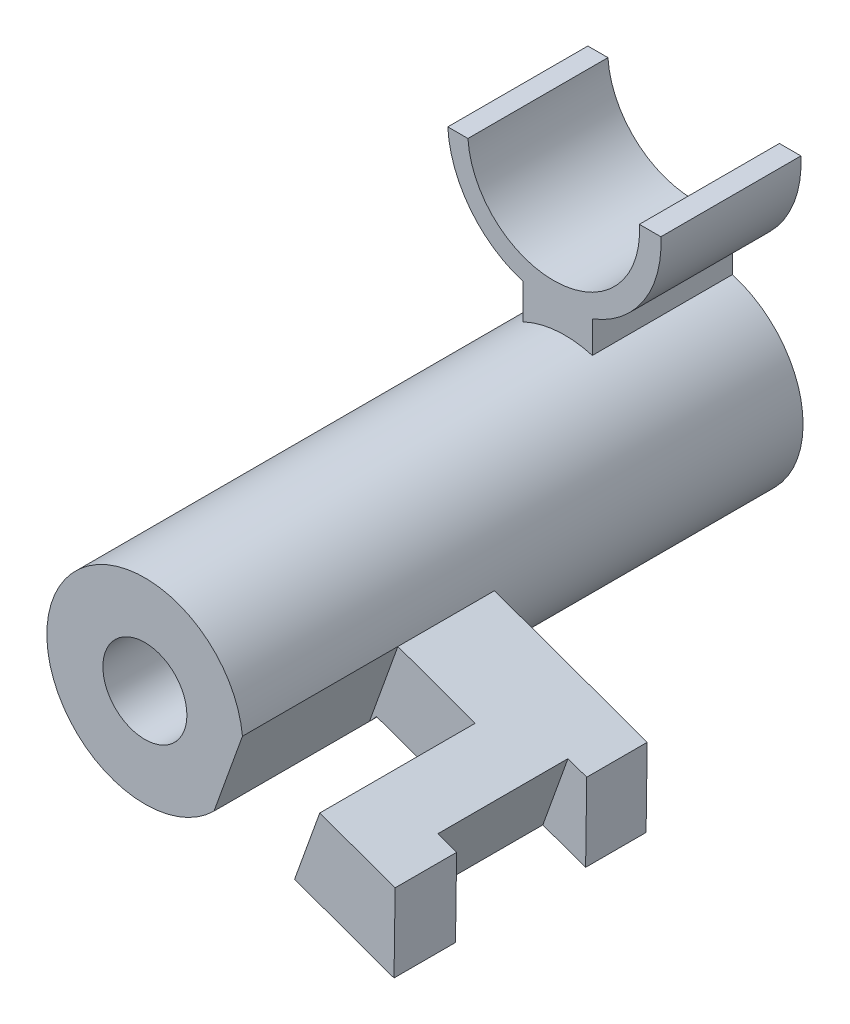
from build123d import *

# Parameters (mm, degrees)
SKETCH3_R           = 17.5
BOSS_EXTRUDE2_DEPTH = 100
SKETCH4_R           = 7.5
CUT_EXTRUDE2_DEPTH  = 100
BOSS_EXTRUDE6_DEPTH = 45
SKETCH18_W          = 14.667250813
SKETCH18_H          = 27.752479941
CUT_EXTRUDE6_DEPTH  = 45
SKETCH19_W          = 15.940771985
SKETCH19_H          = 23.227982035
CUT_EXTRUDE8_DEPTH  = 45
BOSS_EXTRUDE8_DEPTH = 25


with BuildPart() as part:
    # Sketch3 → Boss-Extrude2 (new body)
    with BuildSketch(Plane.XY):
        with Locations((-29.114826613, 50.947684889)):
            Circle(SKETCH3_R)
    extrude(amount=-BOSS_EXTRUDE2_DEPTH)

    # Sketch4 → Cut-Extrude2 (cut)
    with BuildSketch(Plane.XY):
        with Locations((-29.114826613, 50.947684889)):
            Circle(SKETCH4_R)
    extrude(amount=-CUT_EXTRUDE2_DEPTH, mode=Mode.SUBTRACT)

    # Sketch16 → Boss-Extrude6 (add)
    with BuildSketch(Plane.XY):
        Polygon((-11.698148649, 52.653360332), (15.559104196, 42.84895981), (15.359838121, 28.805969908), (-15.52924146, 39.916734066), align=None)
    extrude(amount=-BOSS_EXTRUDE6_DEPTH)

    # Sketch18 → Cut-Extrude6 (cut)
    with BuildSketch(Plane(origin=(15.429488543, 42.895582402, 0), x_dir=(0.940977711, -0.338468532, 0), z_dir=(0.338468532, 0.940977711, 0))):
        with Locations((-21.495577319, 13.876239971)):
            Rectangle(SKETCH18_W, SKETCH18_H)
    extrude(amount=-CUT_EXTRUDE6_DEPTH, mode=Mode.SUBTRACT)

    # Sketch19 → Cut-Extrude8 (cut)
    with BuildSketch(Plane(origin=(15.429488543, 42.895582402, 0), x_dir=(0.940977711, -0.338468532, 0), z_dir=(0.338468532, 0.940977711, 0))):
        with Locations((4.556401634, 22.58985628)):
            Rectangle(SKETCH19_W, SKETCH19_H)
    extrude(amount=-CUT_EXTRUDE8_DEPTH, mode=Mode.SUBTRACT)

    # Sketch20 → Boss-Extrude8 (add)
    with BuildSketch(Plane(origin=(0, 0, -100), x_dir=(-1, 0, 0), z_dir=(0, 0, -1))):
        with BuildLine():
            ThreePointArc((15.84180119, 92.226602563), (30.129018278, 75.909507637), (46.446113204, 90.196724725))
            Line((46.446113204, 90.196724725), (50.037435532, 90.196724725))
            ThreePointArc((50.037435532, 90.196724725), (30.003778847, 72.192945878), (12, 92.226602563))
            Line((12, 92.226602563), (15.84180119, 92.226602563))
        make_face()
        with BuildLine():
            ThreePointArc((36.589403128, 72.998778341), (30.377850806, 72.176669134), (24.235659001, 73.414702098))
            Line((24.235659001, 73.414702098), (24.235659001, 67.753746992))
            ThreePointArc((24.235659001, 67.753746992), (30.50242594, 68.392585809), (36.589403128, 66.771107588))
            Line((36.589403128, 66.771107588), (36.589403128, 72.998778341))
        make_face()
    extrude(amount=-BOSS_EXTRUDE8_DEPTH)


solid = part.part
